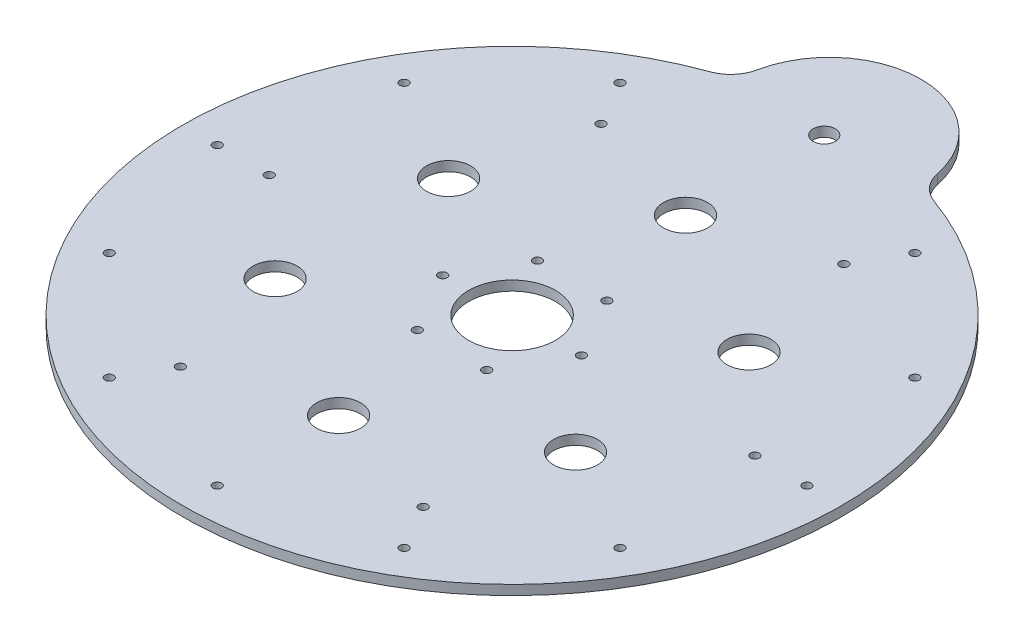
from build123d import *

# Parameters (mm, degrees)
SKETCH1_R             = 25
SKETCH1_R_2           = 12.7
SKETCH1_R_3           = 6.35
BOSS_EXTRUDE1_DEPTH   = 5.6
F_5_0MM_DOWEL_HOLE2_D = 5
F_5_0MM_DOWEL_HOLE3_D = 5
SKETCH10_R            = 12.7
CUT_EXTRUDE1_DEPTH    = 20


with BuildPart() as part:
    # Sketch1 → Boss-Extrude1 (new body)
    with BuildSketch(Plane.XZ):
        with BuildLine():
            ThreePointArc((-51.817317458, -193.490941341), (0, -235.814796706), (51.817317458, -193.490941341))
            ThreePointArc((51.817317458, -193.490941341), (56.278810161, -184.410921807), (64.613246931, -178.676042941))
            ThreePointArc((64.613246931, -178.676042941), (0, 190), (-64.613246931, -178.676042941))
            ThreePointArc((-64.613246931, -178.676042941), (-56.278810161, -184.410921807), (-51.817317458, -193.490941341))
        make_face()
        Circle(SKETCH1_R, mode=Mode.SUBTRACT)
        with Locations((0, 100)):
            Circle(SKETCH1_R_2, mode=Mode.SUBTRACT)
        with Locations((-0.009704669, -179.999999411)):
            Circle(SKETCH1_R_3, mode=Mode.SUBTRACT)
    extrude(amount=BOSS_EXTRUDE1_DEPTH)

    # Ø5.0mm Dowel Hole2 (through all)
    with Locations(Plane(origin=(0, 0, 0), x_dir=(1, 0, 0), z_dir=(0, 1, 0))):
        with Locations((-147.224318643, 85)):
            Hole(F_5_0MM_DOWEL_HOLE2_D / 2)

    # Ø5.0mm Dowel Hole3 (through all)
    with Locations(Plane(origin=(0, 0, 0), x_dir=(1, 0, 0), z_dir=(0, 1, 0))):
        with Locations((-170, 0), (-140, 0), (-147.224318643, 85), (-70, 121.24355653), (-85, 147.224318643), (85, 147.224318643), (70, 121.24355653), (147.224318643, 85), (140, 0), (170, 0), (147.224318643, -85), (70, -121.24355653), (85, -147.224318643), (-85, -147.224318643), (-70, -121.24355653), (-20, -34.641016151), (20, -34.641016151), (40, 0), (-40, 0), (-20, 34.641016151), (20, 34.641016151), (-147.224318643, -85), (0, -170)):
            Hole(F_5_0MM_DOWEL_HOLE3_D / 2)

    # Sketch10 → Cut-Extrude1 (cut)
    with BuildSketch(Plane(origin=(0, 0, 0), x_dir=(-1, 0, 0), z_dir=(0, 1, 0))):
        with Locations((0, 100)):
            Circle(SKETCH10_R)
        with Locations((86.602540378, 50)):
            Circle(SKETCH10_R)
        with Locations((86.602540378, -50)):
            Circle(SKETCH10_R)
        with Locations((0, -100)):
            Circle(SKETCH10_R)
        with Locations((-86.602540378, -50)):
            Circle(SKETCH10_R)
        with Locations((-86.602540378, 50)):
            Circle(SKETCH10_R)
    extrude(amount=-CUT_EXTRUDE1_DEPTH, mode=Mode.SUBTRACT)


solid = part.part
